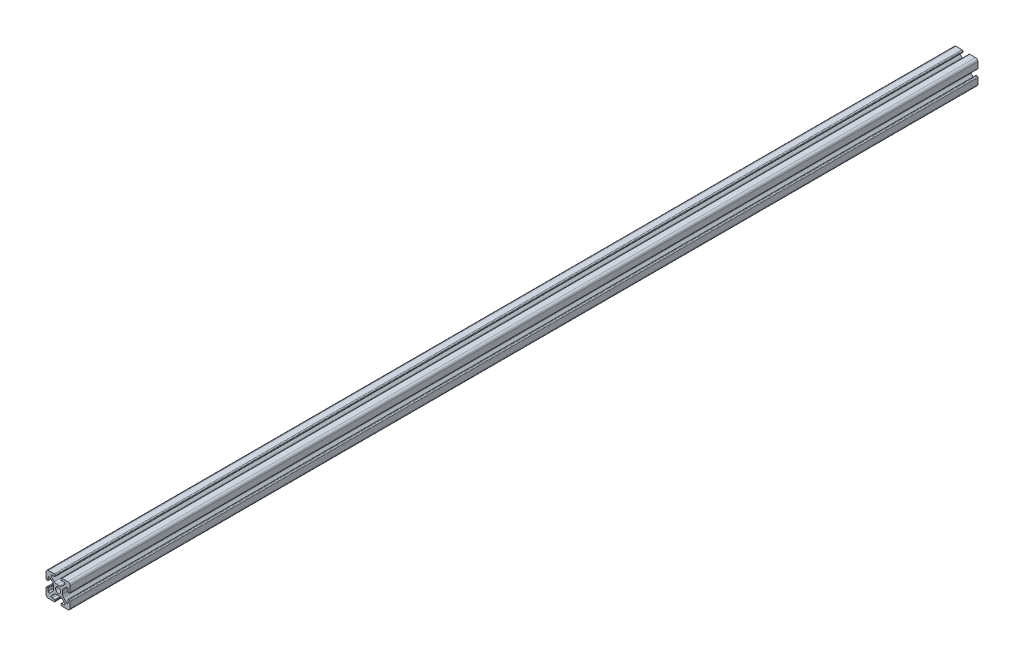
from build123d import *

# Parameters (mm, degrees)
SKETCH3_R                = 2.15
BOSS_EXTRUDE1_DEPTH      = 375
BOSS_EXTRUDE1_DEPTH_BACK = 375


with BuildPart() as part:
    # Sketch3 → Boss-Extrude1 (new body, two sides)
    with BuildSketch(Plane.XY) as boss_extrude1_sk:
        with BuildLine():
            Line((3.2874, 10), (8, 10))
            ThreePointArc((8, 10), (9.414213562, 9.414213562), (10, 8))
            Line((10, 8), (10, 3.2874))
            ThreePointArc((10, 3.2874), (9.76937588, 2.73062412), (9.2126, 2.5))
            Line((9.2126, 2.5), (8.5048, 2.5))
            ThreePointArc((8.5048, 2.5), (8.289273853, 2.589273853), (8.2, 2.8048))
            Line((8.2, 2.8048), (8.2, 4.9118))
            ThreePointArc((8.2, 4.9118), (7.682565253, 5.686195824), (6.769103096, 5.504496904))
            Line((6.769103096, 5.504496904), (4.478679656, 3.214073464))
            ThreePointArc((4.478679656, 3.214073464), (3.828361402, 2.240803418), (3.6, 1.092753121))
            Line((3.6, 1.092753121), (3.6, -1.092753121))
            ThreePointArc((3.6, -1.092753121), (3.828361402, -2.240803418), (4.478679656, -3.214073464))
            Line((4.478679656, -3.214073464), (6.769103096, -5.504496904))
            ThreePointArc((6.769103096, -5.504496904), (7.682565253, -5.686195824), (8.2, -4.9118))
            Line((8.2, -4.9118), (8.2, -2.8048))
            ThreePointArc((8.2, -2.8048), (8.289273853, -2.589273853), (8.5048, -2.5))
            Line((8.5048, -2.5), (9.2126, -2.5))
            ThreePointArc((9.2126, -2.5), (9.76937588, -2.73062412), (10, -3.2874))
            Line((10, -3.2874), (10, -8))
            ThreePointArc((10, -8), (9.414213562, -9.414213562), (8, -10))
            Line((8, -10), (3.2874, -10))
            ThreePointArc((3.2874, -10), (2.73062412, -9.76937588), (2.5, -9.2126))
            Line((2.5, -9.2126), (2.5, -8.5048))
            ThreePointArc((2.5, -8.5048), (2.589273853, -8.289273853), (2.8048, -8.2))
            Line((2.8048, -8.2), (4.9118, -8.2))
            ThreePointArc((4.9118, -8.2), (5.686195824, -7.682565253), (5.504496904, -6.769103096))
            Line((5.504496904, -6.769103096), (3.214073464, -4.478679656))
            ThreePointArc((3.214073464, -4.478679656), (2.240803418, -3.828361402), (1.092753121, -3.6))
            Line((1.092753121, -3.6), (-1.092753121, -3.6))
            ThreePointArc((-1.092753121, -3.6), (-2.240803418, -3.828361402), (-3.214073464, -4.478679656))
            Line((-3.214073464, -4.478679656), (-5.504496904, -6.769103096))
            ThreePointArc((-5.504496904, -6.769103096), (-5.686195824, -7.682565253), (-4.9118, -8.2))
            Line((-4.9118, -8.2), (-2.8048, -8.2))
            ThreePointArc((-2.8048, -8.2), (-2.589273853, -8.289273853), (-2.5, -8.5048))
            Line((-2.5, -8.5048), (-2.5, -9.2126))
            ThreePointArc((-2.5, -9.2126), (-2.73062412, -9.76937588), (-3.2874, -10))
            Line((-3.2874, -10), (-8, -10))
            ThreePointArc((-8, -10), (-9.414213562, -9.414213562), (-10, -8))
            Line((-10, -8), (-10, -3.2874))
            ThreePointArc((-10, -3.2874), (-9.76937588, -2.73062412), (-9.2126, -2.5))
            Line((-9.2126, -2.5), (-8.5048, -2.5))
            ThreePointArc((-8.5048, -2.5), (-8.289273853, -2.589273853), (-8.2, -2.8048))
            Line((-8.2, -2.8048), (-8.2, -4.9118))
            ThreePointArc((-8.2, -4.9118), (-7.682565253, -5.686195824), (-6.769103096, -5.504496904))
            Line((-6.769103096, -5.504496904), (-4.478679656, -3.214073464))
            ThreePointArc((-4.478679656, -3.214073464), (-3.828361402, -2.240803418), (-3.6, -1.092753121))
            Line((-3.6, -1.092753121), (-3.6, 1.092753121))
            ThreePointArc((-3.6, 1.092753121), (-3.828361402, 2.240803418), (-4.478679656, 3.214073464))
            Line((-4.478679656, 3.214073464), (-6.769103096, 5.504496904))
            ThreePointArc((-6.769103096, 5.504496904), (-7.682565253, 5.686195824), (-8.2, 4.9118))
            Line((-8.2, 4.9118), (-8.2, 2.8048))
            ThreePointArc((-8.2, 2.8048), (-8.289273853, 2.589273853), (-8.5048, 2.5))
            Line((-8.5048, 2.5), (-9.2126, 2.5))
            ThreePointArc((-9.2126, 2.5), (-9.76937588, 2.73062412), (-10, 3.2874))
            Line((-10, 3.2874), (-10, 8))
            ThreePointArc((-10, 8), (-9.414213562, 9.414213562), (-8, 10))
            Line((-8, 10), (-3.2874, 10))
            ThreePointArc((-3.2874, 10), (-2.73062412, 9.76937588), (-2.5, 9.2126))
            Line((-2.5, 9.2126), (-2.5, 8.5048))
            ThreePointArc((-2.5, 8.5048), (-2.589273853, 8.289273853), (-2.8048, 8.2))
            Line((-2.8048, 8.2), (-4.9118, 8.2))
            ThreePointArc((-4.9118, 8.2), (-5.686195824, 7.682565253), (-5.504496904, 6.769103096))
            Line((-5.504496904, 6.769103096), (-3.214073464, 4.478679656))
            ThreePointArc((-3.214073464, 4.478679656), (-2.240803418, 3.828361402), (-1.092753121, 3.6))
            Line((-1.092753121, 3.6), (1.092753121, 3.6))
            ThreePointArc((1.092753121, 3.6), (2.240803418, 3.828361402), (3.214073464, 4.478679656))
            Line((3.214073464, 4.478679656), (5.504496904, 6.769103096))
            ThreePointArc((5.504496904, 6.769103096), (5.686195824, 7.682565253), (4.9118, 8.2))
            Line((4.9118, 8.2), (2.8048, 8.2))
            ThreePointArc((2.8048, 8.2), (2.589273853, 8.289273853), (2.5, 8.5048))
            Line((2.5, 8.5048), (2.5, 9.2126))
            ThreePointArc((2.5, 9.2126), (2.73062412, 9.76937588), (3.2874, 10))
        make_face()
        Circle(SKETCH3_R, mode=Mode.SUBTRACT)
    extrude(amount=BOSS_EXTRUDE1_DEPTH)
    extrude(boss_extrude1_sk.sketch, amount=-BOSS_EXTRUDE1_DEPTH_BACK)


solid = part.part
